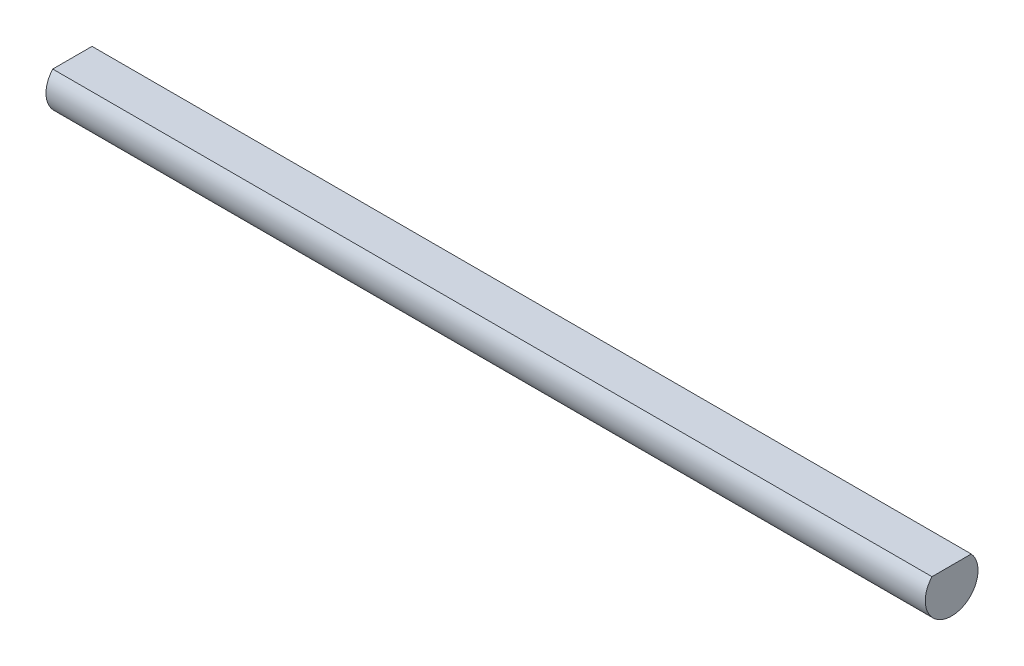
from build123d import *

# Parameters (mm, degrees)
BOSS_EXTRUDE1_DEPTH = 50


with BuildPart() as part:
    # Sketch1 → Boss-Extrude1 (new body, symmetric)
    with BuildSketch(Plane(origin=(0, 0, 0), x_dir=(0, 0, -1), z_dir=(1, 0, 0))):
        with BuildLine():
            Line((-2.236067977, 2), (2.236067977, 2))
            ThreePointArc((2.236067977, 2), (0, -3), (-2.236067977, 2))
        make_face()
    extrude(amount=BOSS_EXTRUDE1_DEPTH, both=True)


solid = part.part
